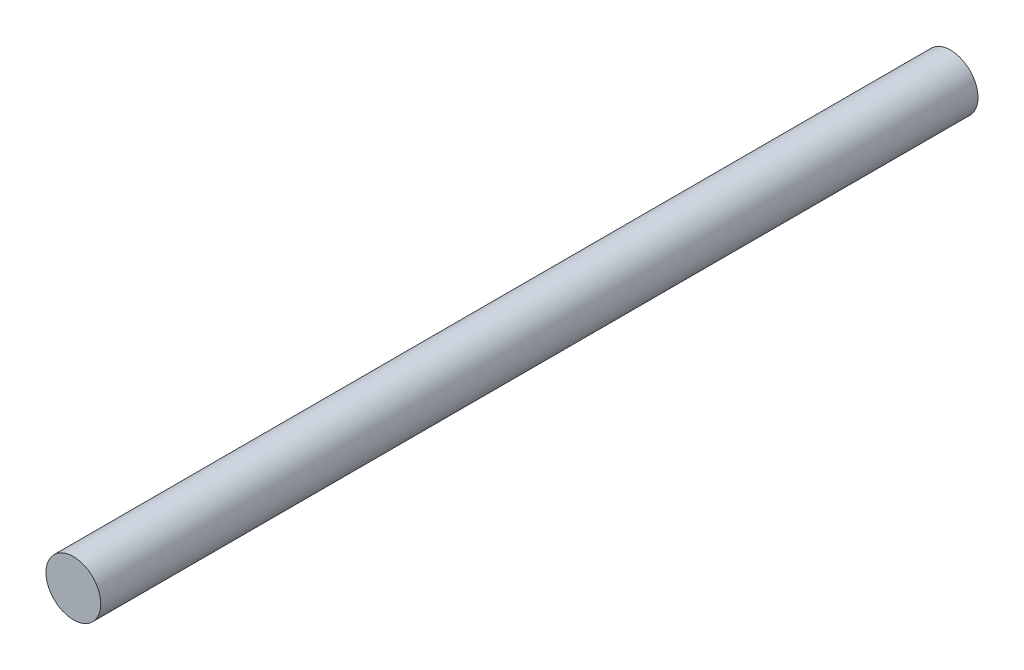
from build123d import *

# Parameters (mm, degrees)
SKETCH2_R           = 5
BOSS_EXTRUDE1_DEPTH = 160


with BuildPart() as part:
    # Sketch2 → Boss-Extrude1 (new body)
    with BuildSketch(Plane.XY):
        Circle(SKETCH2_R)
    extrude(amount=-BOSS_EXTRUDE1_DEPTH)


solid = part.part
